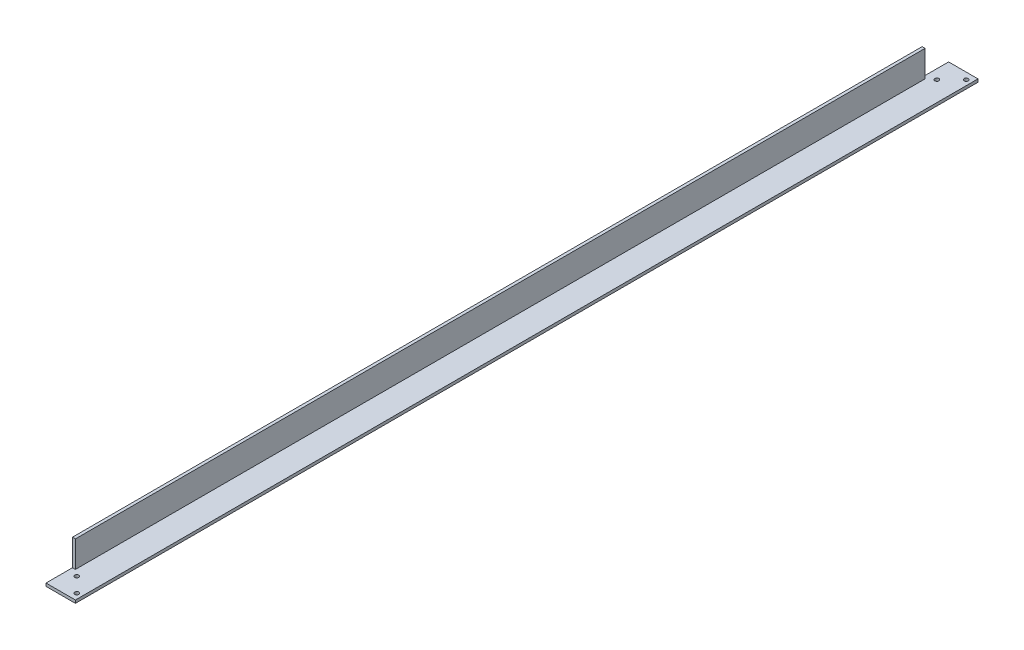
from build123d import *

# Parameters (mm, degrees)
BOSS_EXTRU_1_DEPTH      = 614
ESQUISSE2_W             = 18
ESQUISSE2_H             = 18
ENL_V_MAT_EXTRU_1_DEPTH = 3
ESQUISSE6_R             = 1.4
ENL_V_MAT_EXTRU_5_DEPTH = 3


with BuildPart() as part:
    # Esquisse1 → Boss.-Extru.1 (new body)
    with BuildSketch(Plane.XY):
        Polygon((0, 0), (20, 0), (20, 2), (2, 2), (2, 20), (0, 20), align=None)
    extrude(amount=BOSS_EXTRU_1_DEPTH)

    # Esquisse2 → Enlèv. mat.-Extru.1 (cut, through all)
    with BuildSketch(Plane(origin=(2, 0, 0), x_dir=(0, 0, -1), z_dir=(1, 0, 0))):
        with Locations((-605, 11)):
            Rectangle(ESQUISSE2_W, ESQUISSE2_H)
        with Locations((-9, 11)):
            Rectangle(ESQUISSE2_W, ESQUISSE2_H)
    extrude(amount=-ENL_V_MAT_EXTRU_1_DEPTH, mode=Mode.SUBTRACT)

    # Esquisse6 → Enlèv. mat.-Extru.5 (cut, through all)
    with BuildSketch(Plane(origin=(0, 2, 0), x_dir=(1, 0, 0), z_dir=(0, 1, 0))):
        with Locations((6.48, -599.52)):
            Circle(ESQUISSE6_R)
        with Locations((6.48, -14.48)):
            Circle(ESQUISSE6_R)
        with Locations((16.48, -609.52)):
            Circle(ESQUISSE6_R)
        with Locations((16.48, -4.48)):
            Circle(ESQUISSE6_R)
    extrude(amount=-ENL_V_MAT_EXTRU_5_DEPTH, mode=Mode.SUBTRACT)


solid = part.part
